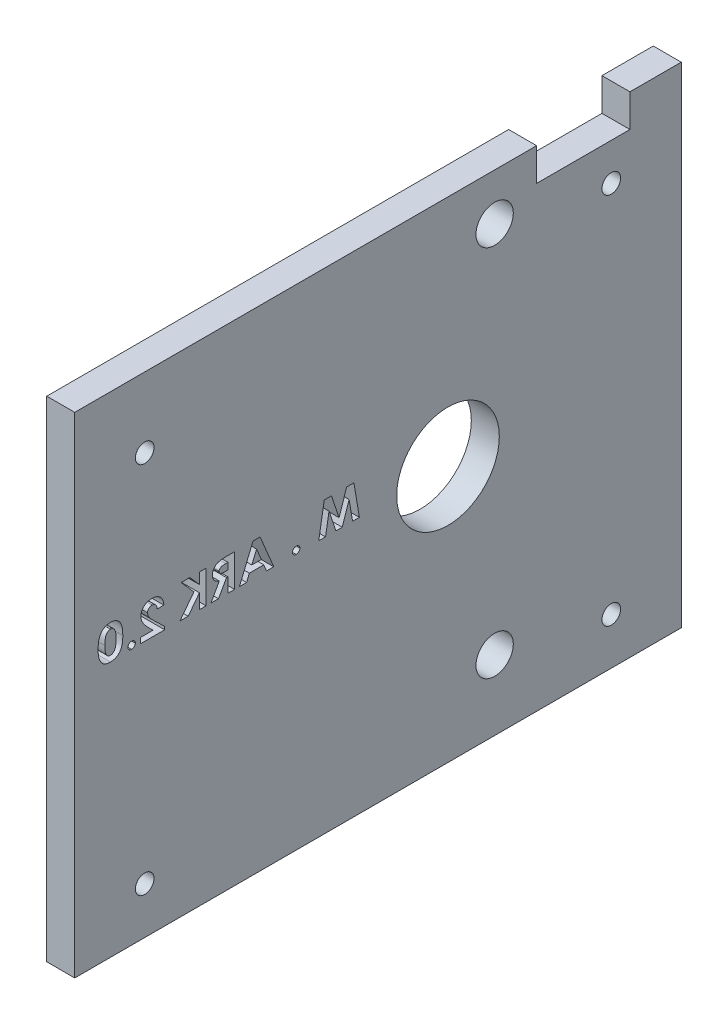
from build123d import *

# Parameters (mm, degrees)
SKETCH1_R           = 4
SKETCH1_R_2         = 11
BOSS_EXTRUDE1_DEPTH = 6
SKETCH4_W           = 50
SKETCH4_H           = 105
BOSS_EXTRUDE2_DEPTH = 6
CUT_EXTRUDE1_REACH  = 8
SKETCH5_R           = 2
CUT_EXTRUDE2_REACH  = 8


with BuildPart() as part:
    # Sketch1 → Boss-Extrude1 (new body)
    with BuildSketch(Plane(origin=(0, 0, 0), x_dir=(0, 0, -1), z_dir=(1, 0, 0))):
        Polygon((-30, 50), (-30, -55), (50, -55), (50, 50), (39, 50), (39, 43), (19, 43), (19, 50), align=None)
        with Locations((10, -40)):
            Circle(SKETCH1_R, mode=Mode.SUBTRACT)
        Circle(SKETCH1_R_2, mode=Mode.SUBTRACT)
        with Locations((10, 40)):
            Circle(SKETCH1_R, mode=Mode.SUBTRACT)
    extrude(amount=BOSS_EXTRUDE1_DEPTH)

    # Sketch4 → Boss-Extrude2 (add)
    with BuildSketch(Plane.ZY):
        with Locations((55, -2.5)):
            Rectangle(SKETCH4_W, SKETCH4_H)
    extrude(amount=-BOSS_EXTRUDE2_DEPTH)

    # Sketch5 → Cut-Extrude1 (cut, up to next)
    with BuildSketch(Plane.ZY, mode=Mode.PRIVATE) as cut_extrude1_sk1:
        with Locations((65, 35)):
            Circle(SKETCH5_R)
    cut_extrude1_tool1 = extrude(cut_extrude1_sk1.sketch, amount=-CUT_EXTRUDE1_REACH, mode=Mode.PRIVATE) & part.part
    add(cut_extrude1_tool1.solids().sort_by_distance((0, 35, 65))[0], mode=Mode.SUBTRACT)
    # Sketch5 → Cut-Extrude1 (cut, up to next)
    with BuildSketch(Plane.ZY, mode=Mode.PRIVATE) as cut_extrude1_sk2:
        with Locations((65, -45)):
            Circle(SKETCH5_R)
    cut_extrude1_tool2 = extrude(cut_extrude1_sk2.sketch, amount=-CUT_EXTRUDE1_REACH, mode=Mode.PRIVATE) & part.part
    add(cut_extrude1_tool2.solids().sort_by_distance((0, -45, 65))[0], mode=Mode.SUBTRACT)
    # Sketch5 → Cut-Extrude1 (cut, up to next)
    with BuildSketch(Plane.ZY, mode=Mode.PRIVATE) as cut_extrude1_sk3:
        with Locations((-35, 35)):
            Circle(SKETCH5_R)
    cut_extrude1_tool3 = extrude(cut_extrude1_sk3.sketch, amount=-CUT_EXTRUDE1_REACH, mode=Mode.PRIVATE) & part.part
    add(cut_extrude1_tool3.solids().sort_by_distance((0, 35, -35))[0], mode=Mode.SUBTRACT)
    # Sketch5 → Cut-Extrude1 (cut, up to next)
    with BuildSketch(Plane.ZY, mode=Mode.PRIVATE) as cut_extrude1_sk4:
        with Locations((-35, -45)):
            Circle(SKETCH5_R)
    cut_extrude1_tool4 = extrude(cut_extrude1_sk4.sketch, amount=-CUT_EXTRUDE1_REACH, mode=Mode.PRIVATE) & part.part
    add(cut_extrude1_tool4.solids().sort_by_distance((0, -45, -35))[0], mode=Mode.SUBTRACT)

    # Sketch6 → Cut-Extrude2 (cut, up to next)
    with BuildSketch(Plane.ZY, mode=Mode.PRIVATE) as cut_extrude2_sk1:
        Polygon((20.166977259, 7), (21.716456426, 7), (23.344461233, 2.117387821), (24.979477259, 7), (26.521945208, 7), (27.697025336, 0), (26.240094246, 0), (25.498307387, 4.421274038), (24.017538157, 0), (22.664373092, 0), (21.19061508, 4.421274038), (20.448828221, 0), (18.991897131, 0), align=None)
    cut_extrude2_tool1 = extrude(cut_extrude2_sk1.sketch, amount=-CUT_EXTRUDE2_REACH, mode=Mode.PRIVATE) & part.part
    add(cut_extrude2_tool1.solids().sort_by_distance((0, 6.888295, 20.941717))[0], mode=Mode.SUBTRACT)
    # Sketch6 → Cut-Extrude2 (cut, up to next)
    with BuildSketch(Plane.ZY, mode=Mode.PRIVATE) as cut_extrude2_sk2:
        with BuildLine():
            add(Edge.make_bspline(
                [(32.543179182, 1.435897436), (32.597177569, 1.433205048), (32.702583484, 1.427949455), (32.854868969, 1.386523443), (32.992980436, 1.314060196), (33.116532751, 1.218225355), (33.220551097, 1.10300538), (33.296728997, 0.971897364), (33.341939739, 0.827405085), (33.347849564, 0.727147203), (33.35087149, 0.67588141)],
                knots=[0, 0, 0, 0, 0.000161867, 0.000315967, 0.000468991, 0.000626904, 0.000782831, 0.000931713, 0.001078521, 0.001232142, 0.001232142, 0.001232142, 0.001232142], degree=3))
            add(Edge.make_bspline(
                [(33.35087149, 0.67588141), (33.347866361, 0.624606727), (33.341989385, 0.524331458), (33.296416467, 0.379574809), (33.220665401, 0.247371838), (33.116536115, 0.130914723), (32.993455717, 0.033252995), (32.854578226, -0.038492689), (32.702850237, -0.082265727), (32.597225409, -0.087212447), (32.543179182, -0.08974359)],
                knots=[0, 0, 0, 0, 0.000153621, 0.000300428, 0.000450528, 0.000607504, 0.00076628, 0.000919304, 0.00107378, 0.001235647, 0.001235647, 0.001235647, 0.001235647], degree=3))
            add(Edge.make_bspline(
                [(32.543179182, -0.08974359), (32.489132955, -0.087212447), (32.383508128, -0.082265727), (32.231780138, -0.038492689), (32.092902648, 0.033252995), (31.969822249, 0.130914723), (31.865692963, 0.247371838), (31.789941897, 0.379574809), (31.744368979, 0.524331458), (31.738492003, 0.624606727), (31.735486874, 0.67588141)],
                knots=[0, 0, 0, 0, 0.000161867, 0.000316343, 0.000469367, 0.000628143, 0.000785119, 0.000935218, 0.001082026, 0.001235647, 0.001235647, 0.001235647, 0.001235647], degree=3))
            add(Edge.make_bspline(
                [(31.735486874, 0.67588141), (31.7385088, 0.727147203), (31.744418625, 0.827405085), (31.789629368, 0.971897364), (31.865807267, 1.10300538), (31.969825614, 1.218225355), (32.093377929, 1.314060196), (32.231489395, 1.386523443), (32.38377488, 1.427949455), (32.489180795, 1.433205048), (32.543179182, 1.435897436)],
                knots=[0, 0, 0, 0, 0.000153621, 0.000300428, 0.000449311, 0.000605238, 0.00076315, 0.000916175, 0.001070275, 0.001232142, 0.001232142, 0.001232142, 0.001232142], degree=3))
        make_face()
    cut_extrude2_tool2 = extrude(cut_extrude2_sk2.sketch, amount=-CUT_EXTRUDE2_REACH, mode=Mode.PRIVATE) & part.part
    add(cut_extrude2_tool2.solids().sort_by_distance((0, 0.673808, 32.543179))[0], mode=Mode.SUBTRACT)
    # Sketch6 → Cut-Extrude2 (cut, up to next)
    with BuildSketch(Plane.ZY, mode=Mode.PRIVATE) as cut_extrude2_sk3:
        Polygon((40.266736874, 7), (41.782562195, 7), (44.703435592, 0), (43.162369887, 0), (42.569220849, 1.435897436), (39.480078221, 1.435897436), (38.885526939, 0), (37.344461233, 0), align=None)
        Polygon((41.023948413, 5.122395833), (40.001712836, 2.692307692), (42.047586233, 2.692307692), align=None, mode=Mode.SUBTRACT)
    cut_extrude2_tool3 = extrude(cut_extrude2_sk3.sketch, amount=-CUT_EXTRUDE2_REACH, mode=Mode.PRIVATE) & part.part
    add(cut_extrude2_tool3.solids().sort_by_distance((0, 6.898435, 41.02465))[0], mode=Mode.SUBTRACT)
    # Sketch6 → Cut-Extrude2 (cut, up to next)
    with BuildSketch(Plane.ZY, mode=Mode.PRIVATE) as cut_extrude2_sk4:
        with BuildLine():
            Line((45.735486874, 7), (47.352273733, 7))
            add(Edge.make_bspline(
                [(47.352273733, 7), (47.458854097, 6.99964909), (47.664118508, 6.998973268), (47.960053777, 6.98862576), (48.232716331, 6.973921557), (48.481163656, 6.952200119), (48.705636033, 6.922535605), (48.905973921, 6.887986841), (49.083423348, 6.848455691), (49.239339304, 6.799914165), (49.379672002, 6.74394769), (49.510550658, 6.680898618), (49.634457791, 6.60872354), (49.752283092, 6.529483973), (49.862189225, 6.44043076), (49.964780164, 6.342906963), (50.061849856, 6.238321934), (50.149972823, 6.124416593), (50.22932825, 6.004276246), (50.300842259, 5.878977723), (50.358688334, 5.746864574), (50.408689552, 5.610427835), (50.446402699, 5.468186336), (50.472882284, 5.320931763), (50.488488556, 5.168071387), (50.490745622, 5.064472559), (50.491897131, 5.01161859)],
                knots=[0, 0, 0, 0, 0.000319724, 0.00061576, 0.000888232, 0.001138838, 0.001363731, 0.001567293, 0.001748595, 0.001908703, 0.002056605, 0.002201477, 0.0023441, 0.002486447, 0.002627042, 0.002767896, 0.002910801, 0.003054694, 0.00319937, 0.003342515, 0.003486885, 0.003631486, 0.003778086, 0.003927713, 0.004079939, 0.004238491, 0.004238491, 0.004238491, 0.004238491], degree=3))
            add(Edge.make_bspline(
                [(50.491897131, 5.01161859), (50.490829381, 4.956424869), (50.488733965, 4.848109461), (50.471979082, 4.68902245), (50.442360845, 4.537145867), (50.401440686, 4.39180298), (50.350072835, 4.253101966), (50.286165025, 4.121208631), (50.210835784, 3.996579862), (50.122533715, 3.879564026), (50.024972066, 3.768409264), (49.913893743, 3.665569952), (49.79252663, 3.568668916), (49.657859209, 3.480748017), (49.513250245, 3.397227929), (49.355883399, 3.322227597), (49.18744922, 3.2530163), (49.069815196, 3.214159591), (49.009725657, 3.194310897)],
                knots=[0, 0, 0, 0, 0.00016556, 0.000324904, 0.000479183, 0.00062923, 0.00077743, 0.000922303, 0.001068278, 0.001213551, 0.001361559, 0.001511363, 0.001667069, 0.001826912, 0.00199336, 0.002167713, 0.00234947, 0.002539265, 0.002539265, 0.002539265, 0.002539265], degree=3))
            Line((49.009725657, 3.194310897), (50.805999695, 0))
            Line((50.805999695, 0), (49.187810592, 0))
            Line((49.187810592, 0), (47.471464439, 3.051282051))
            Line((47.471464439, 3.051282051), (47.17138431, 3.051282051))
            Line((47.17138431, 3.051282051), (47.17138431, 0))
            Line((47.17138431, 0), (45.735486874, 0))
            Line((45.735486874, 0), (45.735486874, 7))
        make_face()
        with BuildLine():
            Line((47.17138431, 4.307692308), (47.684605464, 4.307692308))
            add(Edge.make_bspline(
                [(47.684605464, 4.307692308), (47.747241367, 4.308365235), (47.867412494, 4.30965629), (48.040566482, 4.315685086), (48.198163346, 4.329988559), (48.340767958, 4.348404314), (48.468267403, 4.369008437), (48.579836857, 4.399524012), (48.677173926, 4.431895991), (48.760078917, 4.471555592), (48.830548651, 4.517566693), (48.891629866, 4.569311116), (48.942373356, 4.629419924), (48.985591508, 4.695189512), (49.01546253, 4.770034727), (49.039890094, 4.849534031), (49.054157862, 4.936796852), (49.055369292, 4.997077001), (49.055999695, 5.028445513)],
                knots=[0, 0, 0, 0, 0.000187922, 0.00036054, 0.000519613, 0.000662408, 0.000791969, 0.000906594, 0.001009034, 0.001099346, 0.00118141, 0.001260955, 0.001338524, 0.001416711, 0.001495885, 0.001579292, 0.00166597, 0.001760015, 0.001760015, 0.001760015, 0.001760015], degree=3))
            add(Edge.make_bspline(
                [(49.055999695, 5.028445513), (49.054712275, 5.065581823), (49.052179236, 5.138648661), (49.022312345, 5.243317715), (48.977303831, 5.341440678), (48.911678533, 5.428795897), (48.832827742, 5.508299761), (48.739681513, 5.575341055), (48.634491108, 5.630614118), (48.536779859, 5.665795104), (48.447413838, 5.687716243), (48.366935096, 5.702927041), (48.273240123, 5.715039849), (48.167620527, 5.726396964), (48.048817167, 5.734595134), (47.917426529, 5.740089114), (47.772955022, 5.742466786), (47.672453048, 5.74320514), (47.620102259, 5.743589744)],
                knots=[0, 0, 0, 0, 0.000111096, 0.000218585, 0.000323968, 0.000433352, 0.000544404, 0.00065884, 0.000776135, 0.00089989, 0.000969269, 0.001052049, 0.001145454, 0.001252613, 0.001370702, 0.001502632, 0.00164709, 0.001804148, 0.001804148, 0.001804148, 0.001804148], degree=3))
            Line((47.620102259, 5.743589744), (47.17138431, 5.743589744))
            Line((47.17138431, 5.743589744), (47.17138431, 4.307692308))
        make_face(mode=Mode.SUBTRACT)
    cut_extrude2_tool4 = extrude(cut_extrude2_sk4.sketch, amount=-CUT_EXTRUDE2_REACH, mode=Mode.PRIVATE) & part.part
    add(cut_extrude2_tool4.solids().sort_by_distance((0, 3.653674, 47.886536))[0], mode=Mode.SUBTRACT)
    # Sketch6 → Cut-Extrude2 (cut, up to next)
    with BuildSketch(Plane.ZY, mode=Mode.PRIVATE) as cut_extrude2_sk5:
        Polygon((51.838050977, 7), (53.273948413, 7), (53.273948413, 4.665264423), (55.331039759, 7), (57.182001298, 7), (54.453235272, 3.903846154), (57.447025336, 0), (55.685807387, 0), (53.273948413, 3.145232372), (53.273948413, 0), (51.838050977, 0), align=None)
    cut_extrude2_tool5 = extrude(cut_extrude2_sk5.sketch, amount=-CUT_EXTRUDE2_REACH, mode=Mode.PRIVATE) & part.part
    add(cut_extrude2_tool5.solids().sort_by_distance((0, 3.515313, 53.927793))[0], mode=Mode.SUBTRACT)
    # Sketch6 → Cut-Extrude2 (cut, up to next)
    with BuildSketch(Plane.ZY, mode=Mode.PRIVATE) as cut_extrude2_sk6:
        with BuildLine():
            Line((62.338050977, 4.666666667), (60.902153541, 4.666666667))
            add(Edge.make_bspline(
                [(60.902153541, 4.666666667), (60.90843235, 4.761732597), (60.92071065, 4.947635398), (60.96683863, 5.217644687), (61.030395381, 5.472837629), (61.116146826, 5.711824834), (61.221958314, 5.935606299), (61.348210967, 6.143452783), (61.495115055, 6.335952707), (61.662012025, 6.5102737), (61.844520648, 6.66783936), (62.040688862, 6.805382798), (62.250225109, 6.921752501), (62.472654466, 7.014761753), (62.706350017, 7.090613718), (62.953357448, 7.140842181), (63.212093475, 7.174993966), (63.389149656, 7.177969282), (63.479477259, 7.179487179)],
                knots=[0, 0, 0, 0, 0.000285652, 0.000558596, 0.000820471, 0.001073734, 0.001318982, 0.001561874, 0.001801949, 0.002043957, 0.002284571, 0.002524203, 0.00276146, 0.003002111, 0.00324646, 0.003497278, 0.003757298, 0.004028109, 0.004028109, 0.004028109, 0.004028109], degree=3))
            add(Edge.make_bspline(
                [(63.479477259, 7.179487179), (63.590449597, 7.176419999), (63.806593859, 7.170445958), (64.120841933, 7.119175741), (64.414716305, 7.033417661), (64.688102118, 6.914438207), (64.937617263, 6.761841579), (65.163152312, 6.579903671), (65.360786221, 6.365911314), (65.528006417, 6.126201348), (65.66521865, 5.87236086), (65.764399022, 5.610813274), (65.826501928, 5.346383358), (65.834222536, 5.16852412), (65.838050977, 5.080328526)],
                knots=[0, 0, 0, 0, 0.000332757, 0.000648122, 0.000952073, 0.001249074, 0.001539825, 0.001826933, 0.002115676, 0.002410564, 0.002701654, 0.002979018, 0.00324777, 0.003512122, 0.003512122, 0.003512122, 0.003512122], degree=3))
            add(Edge.make_bspline(
                [(65.838050977, 5.080328526), (65.837094692, 5.026985845), (65.835168186, 4.919523142), (65.815316056, 4.757076849), (65.786467135, 4.59156926), (65.743964233, 4.422969836), (65.688820832, 4.251872124), (65.622313315, 4.077527434), (65.545817694, 3.899632049), (65.454910399, 3.718505067), (65.348479888, 3.531607098), (65.224058795, 3.336643858), (65.076880963, 3.135558481), (64.91245854, 2.924103545), (64.727550813, 2.705283336), (64.523577568, 2.477215404), (64.299106466, 2.241989523), (64.140329383, 2.084743531), (64.058603862, 2.00380609)],
                knots=[0, 0, 0, 0, 0.000159954, 0.000322239, 0.000490304, 0.000663752, 0.000843354, 0.001029303, 0.001223371, 0.001424044, 0.001636931, 0.001868373, 0.002117452, 0.002384207, 0.002671831, 0.002976699, 0.003302019, 0.003647074, 0.003647074, 0.003647074, 0.003647074], degree=3))
            Line((64.058603862, 2.00380609), (63.213050977, 1.166666667))
            Line((63.213050977, 1.166666667), (65.927794567, 1.166666667))
            Line((65.927794567, 1.166666667), (65.927794567, 0))
            Line((65.927794567, 0), (60.722666362, 0))
            Line((60.722666362, 0), (60.722666362, 0.63661859))
            Line((60.722666362, 0.63661859), (63.019541362, 2.842347756))
            add(Edge.make_bspline(
                [(63.019541362, 2.842347756), (63.086173259, 2.906588148), (63.214909722, 3.03070409), (63.397048303, 3.214613454), (63.563334154, 3.387862354), (63.709942753, 3.553114618), (63.839706007, 3.707717303), (63.952640924, 3.852227448), (64.047968946, 3.98731276), (64.149135839, 4.151157055), (64.248827252, 4.344662649), (64.335237881, 4.570266784), (64.391596336, 4.784508877), (64.398737129, 4.924845223), (64.402153541, 4.991987179)],
                knots=[0, 0, 0, 0, 0.000277658, 0.000536451, 0.000776477, 0.000997965, 0.001199048, 0.001381927, 0.001548038, 0.001694745, 0.001959394, 0.002199506, 0.002418871, 0.002620096, 0.002620096, 0.002620096, 0.002620096], degree=3))
            add(Edge.make_bspline(
                [(64.402153541, 4.991987179), (64.399462645, 5.05693329), (64.39423378, 5.183134512), (64.337617517, 5.362347547), (64.2499495, 5.525066693), (64.124968885, 5.664160335), (63.974934781, 5.780316242), (63.800621003, 5.863891481), (63.606102777, 5.914003786), (63.469967829, 5.919983698), (63.399549374, 5.923076923)],
                knots=[0, 0, 0, 0, 0.00019424, 0.000377441, 0.000558178, 0.000744966, 0.000933999, 0.001124027, 0.001320946, 0.001531955, 0.001531955, 0.001531955, 0.001531955], degree=3))
            add(Edge.make_bspline(
                [(63.399549374, 5.923076923), (63.363039239, 5.921929462), (63.291556644, 5.919682868), (63.186150241, 5.903992679), (63.085686659, 5.877264174), (62.989275077, 5.841110841), (62.898496523, 5.792130169), (62.811803865, 5.733673006), (62.730194951, 5.66393461), (62.652738955, 5.58588834), (62.583389312, 5.497518008), (62.52069464, 5.401914132), (62.469304585, 5.29741745), (62.425823324, 5.185605024), (62.38903945, 5.066813034), (62.362578699, 4.940057623), (62.346184091, 4.805850466), (62.340811896, 4.713914893), (62.338050977, 4.666666667)],
                knots=[0, 0, 0, 0, 0.000109519, 0.000214425, 0.000318843, 0.000420928, 0.000522549, 0.000627558, 0.000734027, 0.000844092, 0.000956875, 0.001070448, 0.001186462, 0.001305463, 0.001430105, 0.001559088, 0.00169336, 0.001835326, 0.001835326, 0.001835326, 0.001835326], degree=3))
        make_face()
    cut_extrude2_tool6 = extrude(cut_extrude2_sk6.sketch, amount=-CUT_EXTRUDE2_REACH, mode=Mode.PRIVATE) & part.part
    add(cut_extrude2_tool6.solids().sort_by_distance((0, 4.755345, 61.620102))[0], mode=Mode.SUBTRACT)
    # Sketch6 → Cut-Extrude2 (cut, up to next)
    with BuildSketch(Plane.ZY, mode=Mode.PRIVATE) as cut_extrude2_sk7:
        with BuildLine():
            add(Edge.make_bspline(
                [(67.812409951, 1.435897436), (67.866408339, 1.433205048), (67.971814253, 1.427949455), (68.124099738, 1.386523443), (68.262211205, 1.314060196), (68.38576352, 1.218225355), (68.489781867, 1.10300538), (68.565959766, 0.971897364), (68.611170508, 0.827405085), (68.617080333, 0.727147203), (68.620102259, 0.67588141)],
                knots=[0, 0, 0, 0, 0.000161867, 0.000315967, 0.000468991, 0.000626904, 0.000782831, 0.000931713, 0.001078521, 0.001232142, 0.001232142, 0.001232142, 0.001232142], degree=3))
            add(Edge.make_bspline(
                [(68.620102259, 0.67588141), (68.61709713, 0.624606727), (68.611220154, 0.524331458), (68.565647236, 0.379574809), (68.48989617, 0.247371838), (68.385766884, 0.130914723), (68.262686486, 0.033252995), (68.123808996, -0.038492689), (67.972081006, -0.082265727), (67.866456178, -0.087212447), (67.812409951, -0.08974359)],
                knots=[0, 0, 0, 0, 0.000153621, 0.000300428, 0.000450528, 0.000607504, 0.00076628, 0.000919304, 0.00107378, 0.001235647, 0.001235647, 0.001235647, 0.001235647], degree=3))
            add(Edge.make_bspline(
                [(67.812409951, -0.08974359), (67.758363724, -0.087212447), (67.652738897, -0.082265727), (67.501010907, -0.038492689), (67.362133417, 0.033252995), (67.239053018, 0.130914723), (67.134923732, 0.247371838), (67.059172666, 0.379574809), (67.013599748, 0.524331458), (67.007722772, 0.624606727), (67.004717644, 0.67588141)],
                knots=[0, 0, 0, 0, 0.000161867, 0.000316343, 0.000469367, 0.000628143, 0.000785119, 0.000935218, 0.001082026, 0.001235647, 0.001235647, 0.001235647, 0.001235647], degree=3))
            add(Edge.make_bspline(
                [(67.004717644, 0.67588141), (67.007739569, 0.727147203), (67.013649394, 0.827405085), (67.058860137, 0.971897364), (67.135038036, 1.10300538), (67.239056383, 1.218225355), (67.362608698, 1.314060196), (67.500720165, 1.386523443), (67.65300565, 1.427949455), (67.758411564, 1.433205048), (67.812409951, 1.435897436)],
                knots=[0, 0, 0, 0, 0.000153621, 0.000300428, 0.000449311, 0.000605238, 0.00076315, 0.000916175, 0.001070275, 0.001232142, 0.001232142, 0.001232142, 0.001232142], degree=3))
        make_face()
    cut_extrude2_tool7 = extrude(cut_extrude2_sk7.sketch, amount=-CUT_EXTRUDE2_REACH, mode=Mode.PRIVATE) & part.part
    add(cut_extrude2_tool7.solids().sort_by_distance((0, 0.673808, 67.81241))[0], mode=Mode.SUBTRACT)
    # Sketch6 → Cut-Extrude2 (cut, up to next)
    with BuildSketch(Plane.ZY, mode=Mode.PRIVATE) as cut_extrude2_sk8:
        with BuildLine():
            add(Edge.make_bspline(
                [(72.322025336, 7.179487179), (72.389375958, 7.178550986), (72.522462686, 7.176701042), (72.71822092, 7.157824739), (72.907366189, 7.128264931), (73.089547566, 7.088504811), (73.264029858, 7.034398088), (73.431796097, 6.970323516), (73.591753795, 6.892598758), (73.744817767, 6.804461704), (73.890683838, 6.704263574), (74.027513939, 6.590972105), (74.155890759, 6.464759691), (74.276890322, 6.327724253), (74.387697835, 6.176589519), (74.489817847, 6.013709292), (74.584377157, 5.838733499), (74.670406666, 5.650213935), (74.745689672, 5.445144042), (74.814295536, 5.223357504), (74.866693476, 4.981330953), (74.914283266, 4.721552344), (74.947465, 4.441857845), (74.97542931, 4.143661975), (74.987928772, 3.826359945), (74.990550281, 3.608913033), (74.991897131, 3.497195513)],
                knots=[0, 0, 0, 0, 0.000202001, 0.00039916, 0.000589354, 0.000776126, 0.000957986, 0.001136886, 0.001314374, 0.001490911, 0.001666332, 0.001844616, 0.002023103, 0.002205933, 0.002392437, 0.002584626, 0.002782263, 0.002988717, 0.003205684, 0.003437237, 0.003684545, 0.003948055, 0.004229295, 0.004529159, 0.004846376, 0.005181559, 0.005181559, 0.005181559, 0.005181559], degree=3))
            add(Edge.make_bspline(
                [(74.991897131, 3.497195513), (74.990791619, 3.384061355), (74.988643481, 3.164228588), (74.972906418, 2.84433937), (74.948561518, 2.543432619), (74.91207454, 2.262286079), (74.866515956, 1.999954449), (74.808801936, 1.757100626), (74.742523127, 1.532875368), (74.664807346, 1.327248617), (74.576926433, 1.139529029), (74.484447883, 0.96376789), (74.38365726, 0.802026215), (74.276999579, 0.651695972), (74.161533502, 0.515762152), (74.039928412, 0.391580626), (73.909511296, 0.282036957), (73.773455893, 0.182717335), (73.627868898, 0.097434265), (73.474607846, 0.02196979), (73.310984139, -0.038431547), (73.139627236, -0.091690809), (72.957720054, -0.129571641), (72.767384515, -0.159750435), (72.567711488, -0.176279282), (72.43189518, -0.178404355), (72.3626904, -0.179487179)],
                knots=[0, 0, 0, 0, 0.000339389, 0.000659473, 0.000960612, 0.001244812, 0.001509702, 0.00175901, 0.001993247, 0.002210708, 0.002417747, 0.002614721, 0.002806167, 0.002989062, 0.003167169, 0.003340691, 0.003509822, 0.003677559, 0.003845419, 0.004015374, 0.004189343, 0.004368111, 0.004553212, 0.004746177, 0.004946006, 0.005153614, 0.005153614, 0.005153614, 0.005153614], degree=3))
            add(Edge.make_bspline(
                [(72.3626904, -0.179487179), (72.293016006, -0.17842458), (72.156727835, -0.176346057), (71.956153493, -0.159611666), (71.764823364, -0.129697756), (71.580826843, -0.091071077), (71.406011335, -0.039249955), (71.239317472, 0.024447389), (71.080975881, 0.0982535), (70.931040198, 0.184174548), (70.790613122, 0.283273699), (70.656622347, 0.392959578), (70.530524464, 0.514546973), (70.41396502, 0.649133743), (70.304016651, 0.794123015), (70.201474677, 0.951350589), (70.107990443, 1.121323616), (70.021375919, 1.304033827), (69.943626908, 1.502280704), (69.878772403, 1.720278845), (69.820289754, 1.956697252), (69.777536619, 2.214331564), (69.740061072, 2.49055585), (69.716081172, 2.786854455), (69.700255695, 3.102524233), (69.698123196, 3.319556732), (69.697025336, 3.431290064)],
                knots=[0, 0, 0, 0, 0.00020901, 0.000408838, 0.000603189, 0.000789661, 0.000972459, 0.001149547, 0.001324564, 0.001496057, 0.001667222, 0.001839584, 0.002015111, 0.002192005, 0.002373177, 0.002560643, 0.002754589, 0.002954683, 0.003166909, 0.003392687, 0.003636541, 0.003897045, 0.004175682, 0.004472631, 0.004788512, 0.005123695, 0.005123695, 0.005123695, 0.005123695], degree=3))
            add(Edge.make_bspline(
                [(69.697025336, 3.431290064), (69.698576363, 3.586535489), (69.701569639, 3.886138633), (69.733746774, 4.31894877), (69.780820724, 4.719116088), (69.850046863, 5.086332906), (69.941440562, 5.419958235), (70.049570778, 5.721655748), (70.178667624, 5.991449447), (70.28594135, 6.150432533), (70.337850657, 6.227363782)],
                knots=[0, 0, 0, 0, 0.000465648, 0.00089864, 0.001301281, 0.001673922, 0.002018526, 0.002337918, 0.002634548, 0.002912666, 0.002912666, 0.002912666, 0.002912666], degree=3))
            add(Edge.make_bspline(
                [(70.337850657, 6.227363782), (70.398208089, 6.303307378), (70.517061184, 6.452852032), (70.724333525, 6.646422099), (70.946714503, 6.813085393), (71.189156769, 6.946122593), (71.446970442, 7.052657877), (71.723099192, 7.12680227), (72.016807475, 7.17046333), (72.218575522, 7.176428657), (72.322025336, 7.179487179)],
                knots=[0, 0, 0, 0, 0.000290674, 0.000572382, 0.000848068, 0.001122371, 0.001399696, 0.001683053, 0.001977942, 0.002288221, 0.002288221, 0.002288221, 0.002288221], degree=3))
        make_face()
        with BuildLine():
            add(Edge.make_bspline(
                [(72.354276939, 5.923076923), (72.295119456, 5.920449818), (72.179090774, 5.91529714), (72.010562689, 5.872375592), (71.851561164, 5.80530895), (71.729954495, 5.724610573), (71.638337532, 5.647771122), (71.575383331, 5.577334133), (71.514538291, 5.499417046), (71.460407621, 5.409652856), (71.40858936, 5.311957673), (71.360461597, 5.204341619), (71.317487344, 5.086584843), (71.278261354, 4.958329773), (71.242273247, 4.817735201), (71.214062359, 4.662479302), (71.188779128, 4.492258417), (71.167612037, 4.307097543), (71.152889841, 4.106389032), (71.141736834, 3.890391738), (71.134717255, 3.658965941), (71.133533583, 3.499537548), (71.132922772, 3.417267628)],
                knots=[0, 0, 0, 0, 0.000177238, 0.000347627, 0.000518493, 0.000692733, 0.000783229, 0.000876518, 0.000975523, 0.001079422, 0.001190447, 0.001307196, 0.00143275, 0.001566258, 0.001709438, 0.001867848, 0.002039386, 0.002225674, 0.002426787, 0.002643024, 0.0028745, 0.003121311, 0.003121311, 0.003121311, 0.003121311], degree=3))
            add(Edge.make_bspline(
                [(71.132922772, 3.417267628), (71.134033573, 3.310677961), (71.13616386, 3.106260916), (71.151277185, 2.81242886), (71.177019693, 2.544612166), (71.214998528, 2.302172134), (71.26159029, 2.085004003), (71.318542287, 1.892769589), (71.385959883, 1.725893944), (71.467651294, 1.584776342), (71.55677482, 1.464869084), (71.651271038, 1.360948145), (71.75288013, 1.273242783), (71.860991327, 1.201070006), (71.975902306, 1.145981988), (72.096498297, 1.106315275), (72.223359015, 1.081905532), (72.310232401, 1.078599317), (72.354276939, 1.076923077)],
                knots=[0, 0, 0, 0, 0.000319761, 0.000613235, 0.000882386, 0.001126525, 0.00134904, 0.001548223, 0.001727387, 0.001887574, 0.002035934, 0.002174877, 0.002308112, 0.00243762, 0.002563682, 0.002689173, 0.002817607, 0.002949686, 0.002949686, 0.002949686, 0.002949686], degree=3))
            add(Edge.make_bspline(
                [(72.354276939, 1.076923077), (72.396920468, 1.078067191), (72.480034352, 1.080297113), (72.601262593, 1.103728992), (72.71589845, 1.141744951), (72.823969978, 1.195080237), (72.925106489, 1.26380285), (73.019382214, 1.347087807), (73.106717391, 1.445741928), (73.157160484, 1.519900549), (73.1830029, 1.557892628)],
                knots=[0, 0, 0, 0, 0.000127797, 0.000249081, 0.000368806, 0.000489212, 0.000609388, 0.000734573, 0.000865696, 0.001003437, 0.001003437, 0.001003437, 0.001003437], degree=3))
            add(Edge.make_bspline(
                [(73.1830029, 1.557892628), (73.213203393, 1.609622572), (73.276395394, 1.717863146), (73.350669755, 1.901181732), (73.414612796, 2.107679783), (73.467727353, 2.338709865), (73.507757423, 2.594103598), (73.534255564, 2.873701143), (73.553664717, 3.177214276), (73.555201306, 3.38778571), (73.555999695, 3.497195513)],
                knots=[0, 0, 0, 0, 0.000179509, 0.000375608, 0.000591594, 0.000827655, 0.001086083, 0.001366535, 0.001669967, 0.00199814, 0.00199814, 0.00199814, 0.00199814], degree=3))
            add(Edge.make_bspline(
                [(73.555999695, 3.497195513), (73.554857023, 3.607521076), (73.55265764, 3.819872543), (73.537877831, 4.124945677), (73.51139249, 4.403333159), (73.475500536, 4.654764246), (73.430243335, 4.879972551), (73.37347522, 5.078760233), (73.305271751, 5.250958674), (73.226427414, 5.397830754), (73.13718003, 5.520910135), (73.045293947, 5.629089137), (72.944671243, 5.719120864), (72.839362768, 5.794489494), (72.727157276, 5.853028803), (72.608499807, 5.8936766), (72.483349911, 5.91816267), (72.397857175, 5.921417673), (72.354276939, 5.923076923)],
                knots=[0, 0, 0, 0, 0.000330977, 0.000637055, 0.000915975, 0.00116961, 0.001398692, 0.001604597, 0.001788953, 0.001953351, 0.002103155, 0.002244302, 0.002378339, 0.002507117, 0.002631924, 0.002756535, 0.002882214, 0.003012893, 0.003012893, 0.003012893, 0.003012893], degree=3))
        make_face(mode=Mode.SUBTRACT)
    cut_extrude2_tool8 = extrude(cut_extrude2_sk8.sketch, amount=-CUT_EXTRUDE2_REACH, mode=Mode.PRIVATE) & part.part
    add(cut_extrude2_tool8.solids().sort_by_distance((0, 5.9635, 74.411715))[0], mode=Mode.SUBTRACT)


solid = part.part
